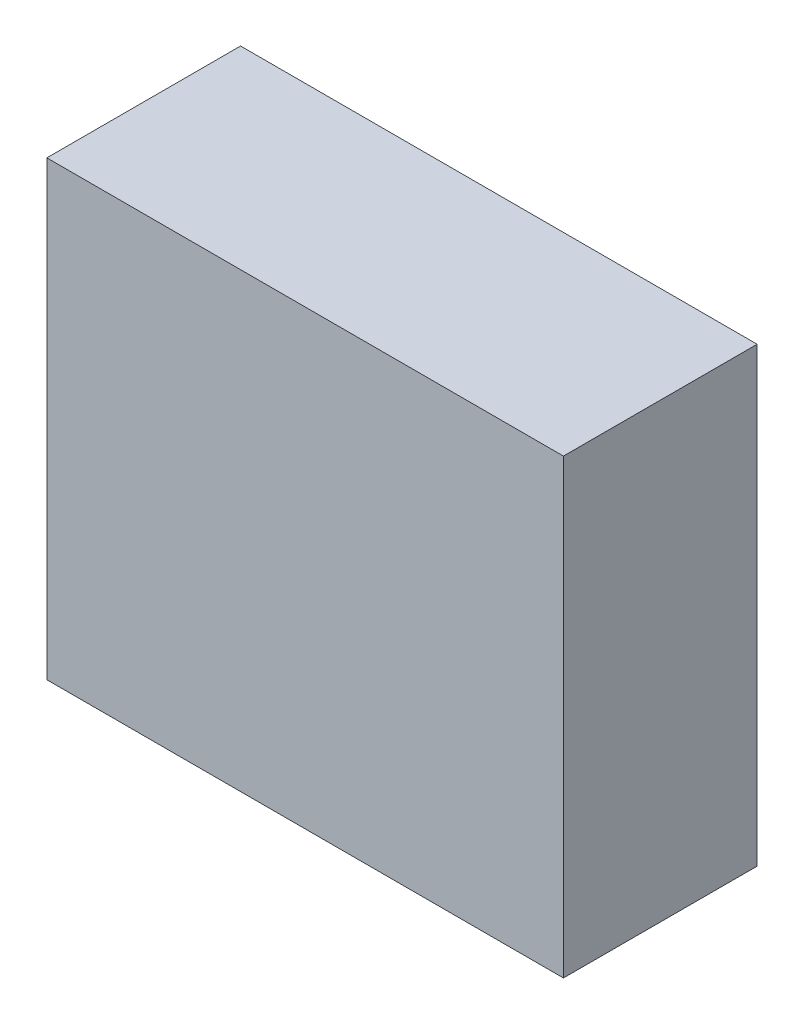
from build123d import *

# Parameters (mm, degrees)
SKETCH1_W           = 406.4
SKETCH1_H           = 152.4
BOSS_EXTRUDE1_DEPTH = 355.6


with BuildPart() as part:
    # Sketch1 → Boss-Extrude1 (new body)
    with BuildSketch(Plane(origin=(0, 0, 0), x_dir=(1, 0, 0), z_dir=(0, 1, 0))):
        Rectangle(SKETCH1_W, SKETCH1_H)
    extrude(amount=BOSS_EXTRUDE1_DEPTH)


solid = part.part
